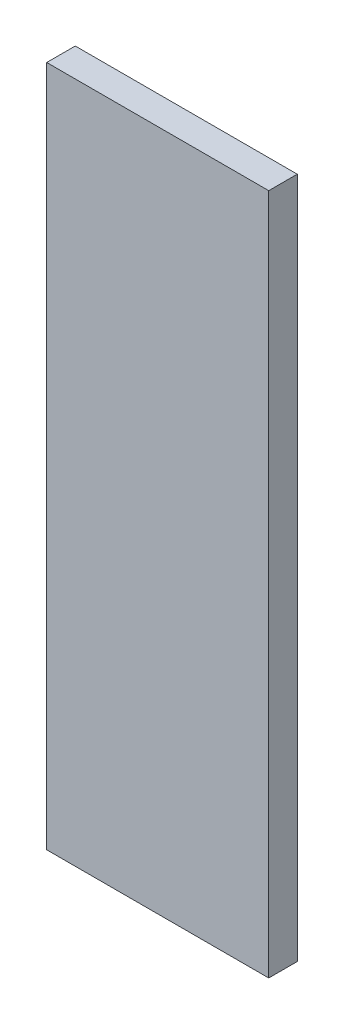
from build123d import *

# Parameters (mm, degrees)
SKETCH1_W           = 140
SKETCH1_H           = 430
BOSS_EXTRUDE1_DEPTH = 18


with BuildPart() as part:
    # Sketch1 → Boss-Extrude1 (new body)
    with BuildSketch(Plane.XY):
        Rectangle(SKETCH1_W, SKETCH1_H)
    extrude(amount=BOSS_EXTRUDE1_DEPTH)


solid = part.part
